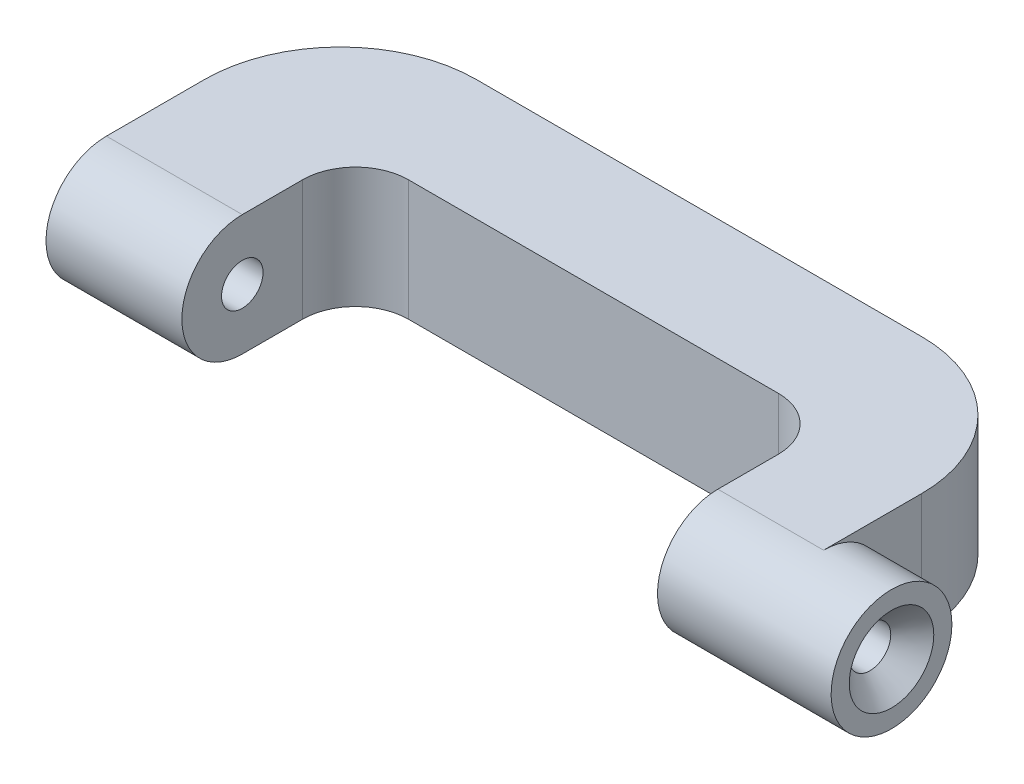
from build123d import *

# Parameters (mm, degrees)
SKETCH1_R                                       = 8
BOSS_EXTRUDE1_DEPTH                             = 18
SKETCH3_R                                       = 8
BOSS_EXTRUDE2_DEPTH                             = 23
BOSS_EXTRUDE3_DEPTH                             = 8
CSK_FOR_M5_FLAT_HEAD_MACHINE_SCREW1_D           = 5.5
CSK_FOR_M5_FLAT_HEAD_MACHINE_SCREW1_CSINK_D     = 11.2
CSK_FOR_M5_FLAT_HEAD_MACHINE_SCREW1_CSINK_ANGLE = 90


with BuildPart() as part:
    # Sketch1 → Boss-Extrude1 (new body)
    with BuildSketch(Plane.YZ):
        Circle(SKETCH1_R)
    extrude(amount=BOSS_EXTRUDE1_DEPTH)



with BuildPart() as body_2:
    # Sketch3 → Boss-Extrude2 (new body)
    with BuildSketch(Plane(origin=(81, 0, 0), x_dir=(0, 0, -1), z_dir=(1, 0, 0))):
        Circle(SKETCH3_R)
    extrude(amount=BOSS_EXTRUDE2_DEPTH)


with BuildPart() as part_1:
    add(part.part)

    add(body_2.part)  # Boss-Extrude3 merges body 2
    # Sketch7 → Boss-Extrude3 (add, symmetric)
    with BuildSketch(Plane(origin=(0, 0, 0), x_dir=(-1, 0, 0), z_dir=(0, 1, 0))):
        with BuildLine():
            Line((0, 0), (0, -13))
            ThreePointArc((0, -13), (-5.272077939, -25.727922061), (-18, -31))
            Line((-18, -31), (-77, -31))
            ThreePointArc((-77, -31), (-89.727922061, -25.727922061), (-95, -13))
            Line((-95, -13), (-95, 0))
            Line((-95, 0), (-81, 0))
            Line((-81, 0), (-81, -8))
            ThreePointArc((-81, -8), (-78.949747468, -12.949747468), (-74, -15))
            Line((-74, -15), (-25, -15))
            ThreePointArc((-25, -15), (-20.050252532, -12.949747468), (-18, -8))
            Line((-18, -8), (-18, 0))
            Line((-18, 0), (0, 0))
        make_face()
    extrude(amount=BOSS_EXTRUDE3_DEPTH, both=True)

    # CSK for M5 Flat Head Machine Screw1 (through all)
    with Locations(Plane.YZ.offset(104)):
        with Locations((0, 0)):
            CounterSinkHole(CSK_FOR_M5_FLAT_HEAD_MACHINE_SCREW1_D / 2, CSK_FOR_M5_FLAT_HEAD_MACHINE_SCREW1_CSINK_D / 2, counter_sink_angle=CSK_FOR_M5_FLAT_HEAD_MACHINE_SCREW1_CSINK_ANGLE)


solid = part_1.part
